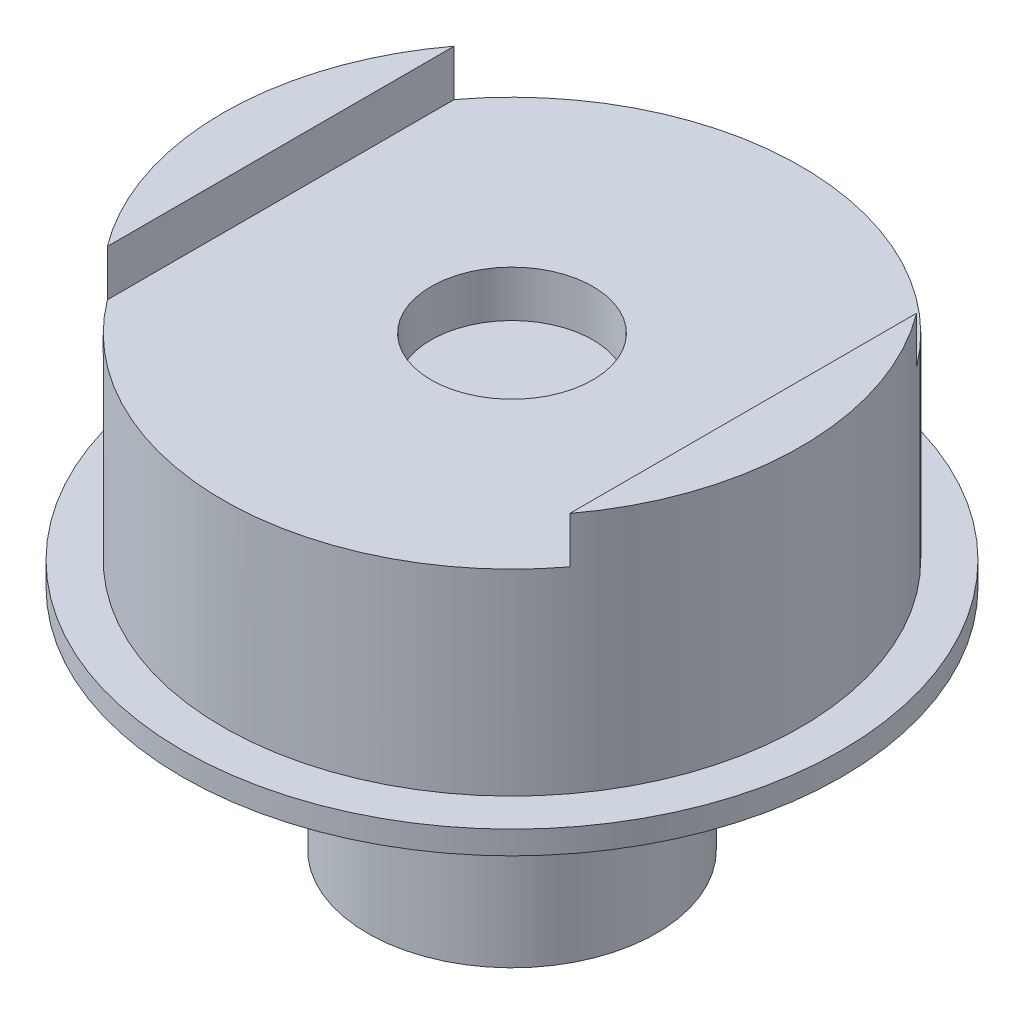
from build123d import *

# Parameters (mm, degrees)
SKETCH_2_W          = 40
SKETCH_2_H          = 57
CUT_EXTRUDE_1_DEPTH = 4
SKETCH_3_R          = 7
CUT_EXTRUDE_3_DEPTH = 4


with BuildPart() as part:
    # 草圖1 → 旋轉1 (revolve)
    with BuildSketch(Plane.XY):
        Polygon((0, 21), (25, 21), (25, 0), (28.5, 0), (28.5, -2), (12.5, -2), (12.5, -21.7), (8, -21.7), (8, 2.3), (0, 2.3), align=None)
    revolve(axis=Axis((0, 41.921070153, 0), (0, -1, 0)))

    # 草圖2 → 除料-伸長1 (cut)
    with BuildSketch(Plane(origin=(0, 21, 0), x_dir=(1, 0, 0), z_dir=(0, 1, 0))):
        Rectangle(SKETCH_2_W, SKETCH_2_H)
    extrude(amount=-CUT_EXTRUDE_1_DEPTH, mode=Mode.SUBTRACT)

    # 草圖3 → 除料-伸長3 (cut)
    with BuildSketch(Plane(origin=(0, 17, 0), x_dir=(1, 0, 0), z_dir=(0, 1, 0))):
        Circle(SKETCH_3_R)
    extrude(amount=-CUT_EXTRUDE_3_DEPTH, mode=Mode.SUBTRACT)


solid = part.part
